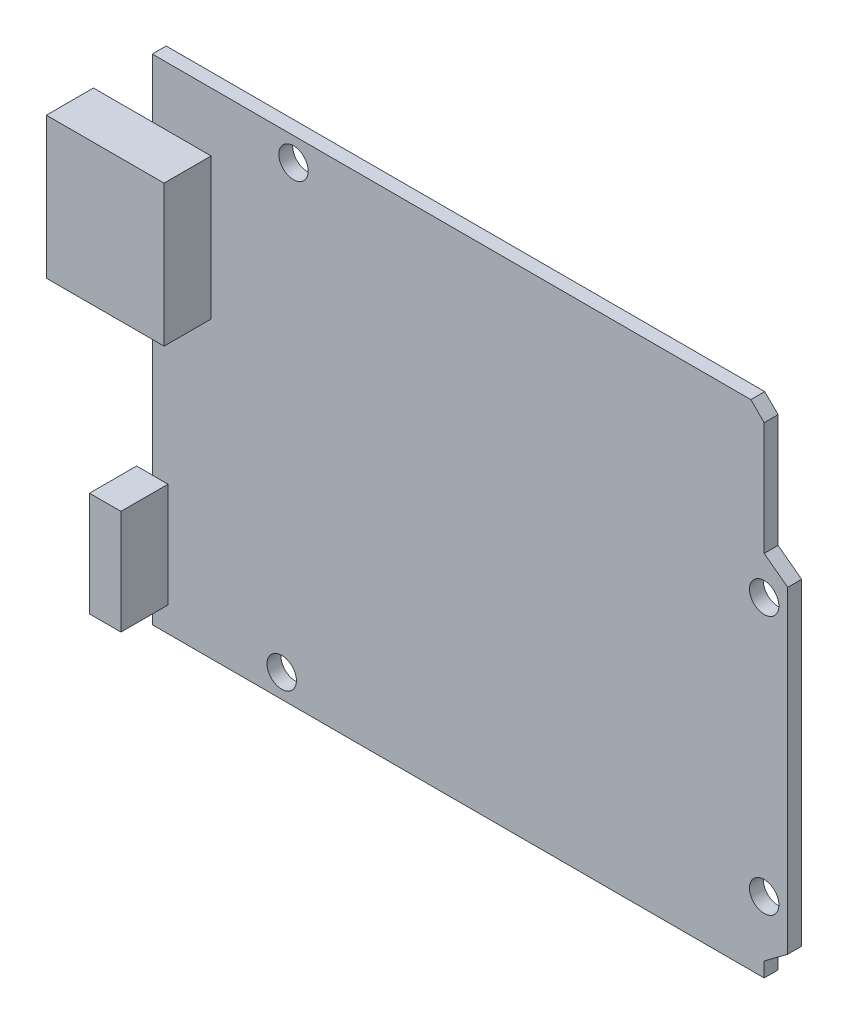
from build123d import *

# Parameters (mm, degrees)
SKETCH1_W           = 68.58
SKETCH1_H           = 53.34
BOSS_EXTRUDE1_DEPTH = 1.5
SKETCH2_W           = 12.7
SKETCH2_H           = 15.24
SKETCH2_W_2         = 3.39503639
SKETCH2_H_2         = 11.2855496
BOSS_EXTRUDE2_DEPTH = 5.08
SKETCH3_R           = 1.5875
CUT_EXTRUDE1_DEPTH  = 10.16
CUT_EXTRUDE2_DEPTH  = 2.5


with BuildPart() as part:
    # Sketch1 → Boss-Extrude1 (new body)
    with BuildSketch(Plane.XY):
        Rectangle(SKETCH1_W, SKETCH1_H)
    extrude(amount=BOSS_EXTRUDE1_DEPTH)

    # Sketch2 → Boss-Extrude2 (add)
    with BuildSketch(Plane.XY.offset(1.5)):
        with Locations((-34.29, 12.7)):
            Rectangle(SKETCH2_W, SKETCH2_H)
        with Locations((-34.29, -18.328779787)):
            Rectangle(SKETCH2_W_2, SKETCH2_H_2)
    extrude(amount=BOSS_EXTRUDE2_DEPTH)

    # Sketch3 → Cut-Extrude1 (cut)
    with BuildSketch(Plane.XY.offset(1.5)):
        with Locations((-19.05, 24.13)):
            Circle(SKETCH3_R)
        with Locations((-20.32, -24.13)):
            Circle(SKETCH3_R)
        with Locations((31.75, 8.89)):
            Circle(SKETCH3_R)
        with Locations((31.75, -19.05)):
            Circle(SKETCH3_R)
    extrude(amount=-CUT_EXTRUDE1_DEPTH, mode=Mode.SUBTRACT)

    # Sketch4 → Cut-Extrude2 (cut, through all)
    with BuildSketch(Plane.XY.offset(1.5)):
        Polygon((30.313159021, 26.67), (31.75, 25.233159021), (31.75, 13.012702255), (34.29, 11.115796447), (34.29, 26.67), align=None)
        Polygon((34.29, -23.181547096), (31.75, -25.078452904), (31.75, -26.67), (34.29, -26.67), align=None)
    extrude(amount=-CUT_EXTRUDE2_DEPTH, mode=Mode.SUBTRACT)


solid = part.part
